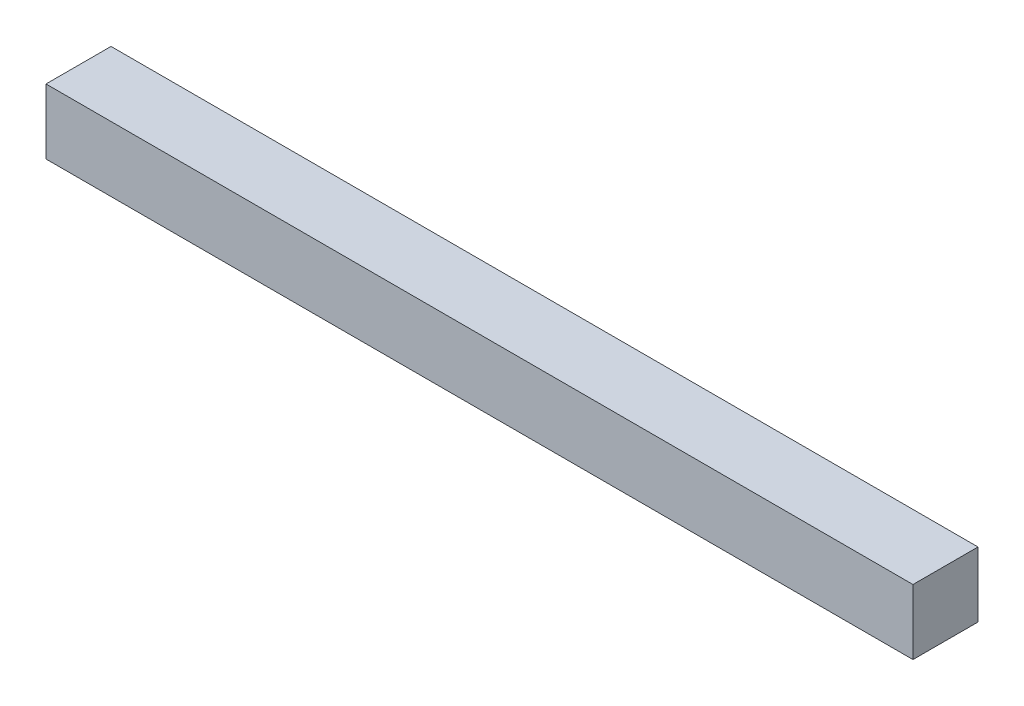
from build123d import *

# Parameters (mm, degrees)
SKETCH1_W           = 4.7625
SKETCH1_H           = 4.7625
BOSS_EXTRUDE1_DEPTH = 63.5


with BuildPart() as part:
    # Sketch1 → Boss-Extrude1 (new body)
    with BuildSketch(Plane(origin=(0, 0, 0), x_dir=(0, 0, -1), z_dir=(1, 0, 0))):
        Rectangle(SKETCH1_W, SKETCH1_H)
    extrude(amount=BOSS_EXTRUDE1_DEPTH)


solid = part.part
